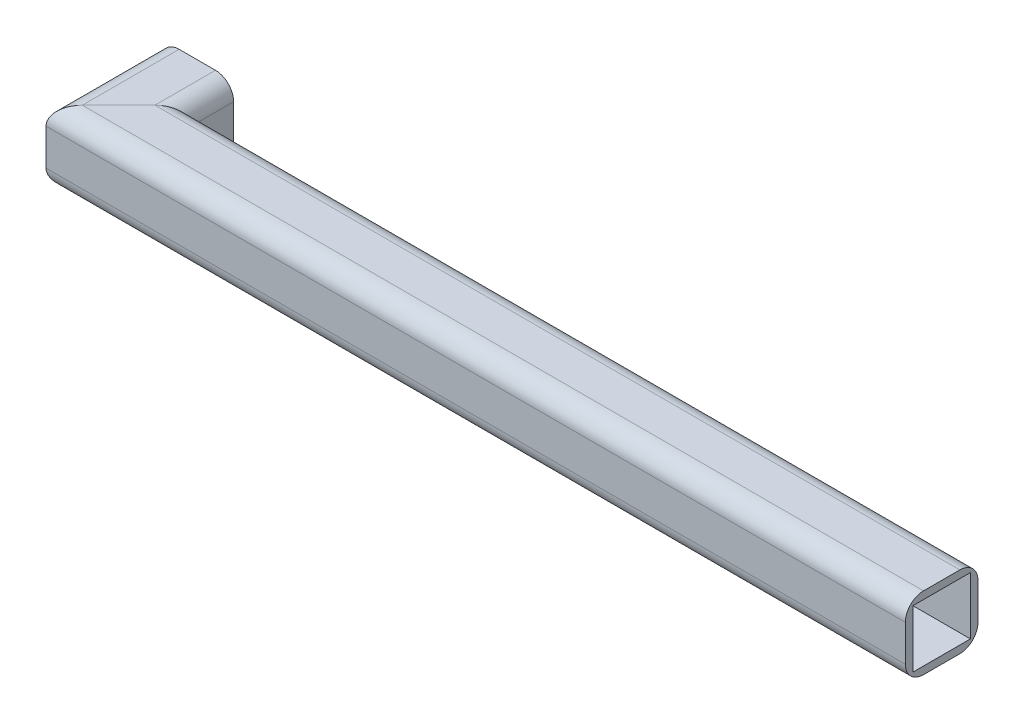
from build123d import *

# Parameters (mm, degrees)
SKETCH12_W = 120.65
SKETCH12_H = 120.65


with BuildPart() as part:
    # Sweep1: sweep along a curve in space
    with BuildLine() as sweep1_path:
        Line((60.325, 60.325, 0), (60.325, 60.325, 165.1))
        Line((60.325, 60.325, 165.1), (1787.525, 60.325, 165.1))
    # Sketch12 → Sweep1 (sweep)
    with BuildSketch(Plane.XY):
        with BuildLine():
            Line((22.225, 136.525), (98.425, 136.525))
            ThreePointArc((98.425, 136.525), (125.365768363, 125.365768363), (136.525, 98.425))
            Line((136.525, 98.425), (136.525, 22.225))
            ThreePointArc((136.525, 22.225), (125.365768363, -4.715768363), (98.425, -15.875))
            Line((98.425, -15.875), (22.225, -15.875))
            ThreePointArc((22.225, -15.875), (-4.715768363, -4.715768363), (-15.875, 22.225))
            Line((-15.875, 22.225), (-15.875, 98.425))
            ThreePointArc((-15.875, 98.425), (-4.715768363, 125.365768363), (22.225, 136.525))
        make_face()
        with Locations((60.325, 60.325)):
            Rectangle(SKETCH12_W, SKETCH12_H, mode=Mode.SUBTRACT)
    sweep(path=sweep1_path.line, transition=Transition.RIGHT)


solid = part.part
